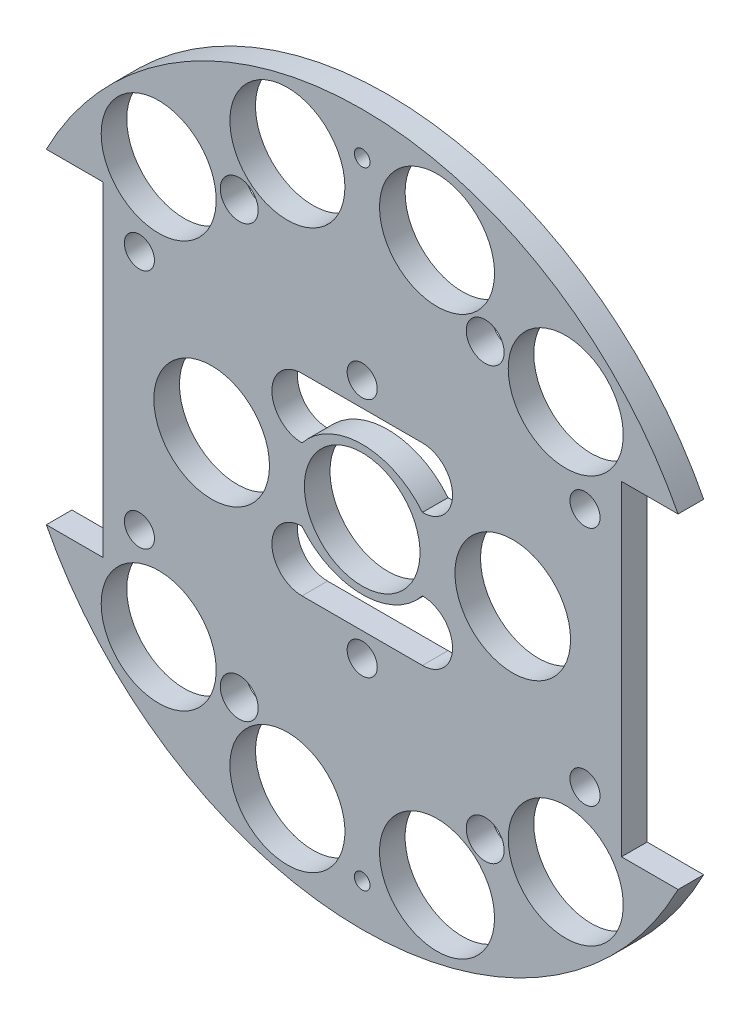
from build123d import *

# Parameters (mm, degrees)
SKETCH1_R                = 1.651
BOSS_EXTRUDE2_DEPTH      = 5.3975
SKETCH4_W                = 37.082318314
SKETCH4_H                = 34.047903563
SKETCH4_W_2              = 37.024578492
SKETCH4_H_2              = 32.488734362
BOSS_EXTRUDE3_DEPTH      = 5.3975
SKETCH3_R                = 12.192
SKETCH3_R_2              = 12.1285
CUT_EXTRUDE2_DEPTH       = 101.410849545
SKETCH12_R               = 4
CUT_EXTRUDE10_DEPTH      = 83.312
SKETCH15_R               = 1.651
CUT_EXTRUDE17_DEPTH      = 83.312
SKETCH35_R               = 3.175
CUT_EXTRUDE37_DEPTH      = 103.378
CUT_EXTRUDE37_DEPTH_BACK = 48.768
SKETCH40_R               = 12.192
CUT_EXTRUDE43_DEPTH      = 25.4


with BuildPart() as part:
    # Sketch1 → Boss-Extrude2 (new body)
    with BuildSketch(Plane.XY):
        with BuildLine():
            Line((-66.623575407, 34.29), (-54.685575407, 34.29))
            Line((-54.685575407, 34.29), (-54.685575407, -34.29))
            Line((-54.685575407, -34.29), (-66.623575407, -34.29))
            ThreePointArc((-66.623575407, -34.29), (0, -74.93), (66.623575407, -34.29))
            Line((66.623575407, -34.29), (54.685575407, -34.29))
            Line((54.685575407, -34.29), (54.685575407, 34.29))
            Line((54.685575407, 34.29), (66.623575407, 34.29))
            ThreePointArc((66.623575407, 34.29), (0, 74.93), (-66.623575407, 34.29))
        make_face()
        with Locations((-45.466, 11.049)):
            Circle(SKETCH1_R, mode=Mode.SUBTRACT)
        with Locations((-20.067270032, 10.795)):
            Circle(SKETCH1_R, mode=Mode.SUBTRACT)
        with Locations(Location((-20.067270032, -10.795, 0), (0, 0, 180))):
            Circle(SKETCH1_R, mode=Mode.SUBTRACT)
        with Locations(Location((-45.466, -11.049, 0), (0, 0, 180))):
            Circle(SKETCH1_R, mode=Mode.SUBTRACT)
        with Locations((45.466, -11.049)):
            Circle(SKETCH1_R, mode=Mode.SUBTRACT)
        with Locations((20.067270032, -10.795)):
            Circle(SKETCH1_R, mode=Mode.SUBTRACT)
        with Locations(Location((20.067270032, 10.795, 0), (0, 0, 180))):
            Circle(SKETCH1_R, mode=Mode.SUBTRACT)
        with Locations(Location((45.466, 11.049, 0), (0, 0, 180))):
            Circle(SKETCH1_R, mode=Mode.SUBTRACT)
    extrude(amount=BOSS_EXTRUDE2_DEPTH)

    # Sketch4 → Boss-Extrude3 (add)
    with BuildSketch(Plane(origin=(0, 0, 0), x_dir=(-1, 0, 0), z_dir=(0, 0, -1))):
        with Locations((32.991199211, -1.421154886)):
            Rectangle(SKETCH4_W, SKETCH4_H)
        with Locations((-34.085074962, -0.641570285)):
            Rectangle(SKETCH4_W_2, SKETCH4_H_2)
    extrude(amount=-BOSS_EXTRUDE3_DEPTH)

    # Sketch3 → Cut-Extrude2 (cut, through all)
    with BuildSketch(Plane(origin=(0, 0, 0), x_dir=(-1, 0, 0), z_dir=(0, 0, -1))):
        Circle(SKETCH3_R)
        with Locations((-42.926, -42.926)):
            Circle(SKETCH3_R_2)
        with Locations((15.777608989, -58.882838371)):
            Circle(SKETCH3_R_2)
        with Locations(Location((15.777608989, 58.882838371, 0), (0, 0, 180))):
            Circle(SKETCH3_R_2)
        with Locations((-42.926, 42.926)):
            Circle(SKETCH3_R_2)
        with Locations((42.926, 42.926)):
            Circle(SKETCH3_R_2)
        with Locations((-15.777608989, 58.882838371)):
            Circle(SKETCH3_R_2)
        with Locations(Location((-15.777608989, -58.882838371, 0), (0, 0, 180))):
            Circle(SKETCH3_R_2)
        with Locations((42.926, -42.926)):
            Circle(SKETCH3_R_2)
    extrude(amount=-CUT_EXTRUDE2_DEPTH, mode=Mode.SUBTRACT)

    # Sketch12 → Cut-Extrude10 (cut)
    with BuildSketch(Plane(origin=(0, 0, 0), x_dir=(-1, 0, 0), z_dir=(0, 0, -1))):
        with Locations((25.937608989, 45.466)):
            Circle(SKETCH12_R)
        with Locations((25.937608989, -45.466)):
            Circle(SKETCH12_R)
        with Locations(Location((-25.937608989, 45.466, 0), (0, 0, 180))):
            Circle(SKETCH12_R)
        with Locations(Location((-25.937608989, -45.466, 0), (0, 0, 180))):
            Circle(SKETCH12_R)
    extrude(amount=-CUT_EXTRUDE10_DEPTH, mode=Mode.SUBTRACT)

    # Sketch15 → Cut-Extrude17 (cut)
    with BuildSketch(Plane(origin=(0, 0, 0), x_dir=(-1, 0, 0), z_dir=(0, 0, -1))):
        with Locations((0, 66.04)):
            Circle(SKETCH15_R)
        with Locations(Location((0, -66.04, 0), (0, 0, 180))):
            Circle(SKETCH15_R)
    extrude(amount=-CUT_EXTRUDE17_DEPTH, mode=Mode.SUBTRACT)

    # Sketch35 → Cut-Extrude37 (cut, two sides)
    with BuildSketch(Plane(origin=(-30.092005081, 4.08352975, -36.1315), x_dir=(1, 0, 0), z_dir=(0, 0, 1))) as cut_extrude37_sk:
        with Locations((-16.897994919, 21.31647025)):
            Circle(SKETCH35_R)
        with Locations((77.082005081, 21.31647025)):
            Circle(SKETCH35_R)
        with Locations((30.092005081, 21.31647025)):
            Circle(SKETCH35_R)
        with Locations((77.082005081, -29.48352975)):
            Circle(SKETCH35_R)
        with Locations((30.092005081, -29.48352975)):
            Circle(SKETCH35_R)
        with Locations((-16.897994919, -29.48352975)):
            Circle(SKETCH35_R)
    extrude(amount=CUT_EXTRUDE37_DEPTH, mode=Mode.SUBTRACT)
    extrude(cut_extrude37_sk.sketch, amount=-CUT_EXTRUDE37_DEPTH_BACK, mode=Mode.SUBTRACT)

    # Sketch40 → Cut-Extrude43 (cut)
    with BuildSketch(Plane(origin=(0, 0, 0), x_dir=(-1, 0, 0), z_dir=(0, 0, -1))):
        with Locations((-31.75, 0)):
            Circle(SKETCH40_R)
        with Locations((31.75, 0)):
            Circle(SKETCH40_R)
        with BuildLine():
            Line((12.7, -20.32), (-12.7, -20.32))
            ThreePointArc((-12.7, -20.32), (-19.05, -13.97), (-12.7, -7.62))
            ThreePointArc((-12.7, -7.62), (0, -13.723935563), (12.7, -7.62))
            ThreePointArc((12.7, -7.62), (19.05, -13.97), (12.7, -20.32))
        make_face()
        with BuildLine():
            Line((12.7, 20.32), (-12.7, 20.32))
            ThreePointArc((-12.7, 20.32), (-19.05, 13.97), (-12.7, 7.62))
            ThreePointArc((-12.7, 7.62), (0, 13.723935563), (12.7, 7.62))
            ThreePointArc((12.7, 7.62), (19.05, 13.97), (12.7, 20.32))
        make_face()
    extrude(amount=-CUT_EXTRUDE43_DEPTH, mode=Mode.SUBTRACT)


solid = part.part
